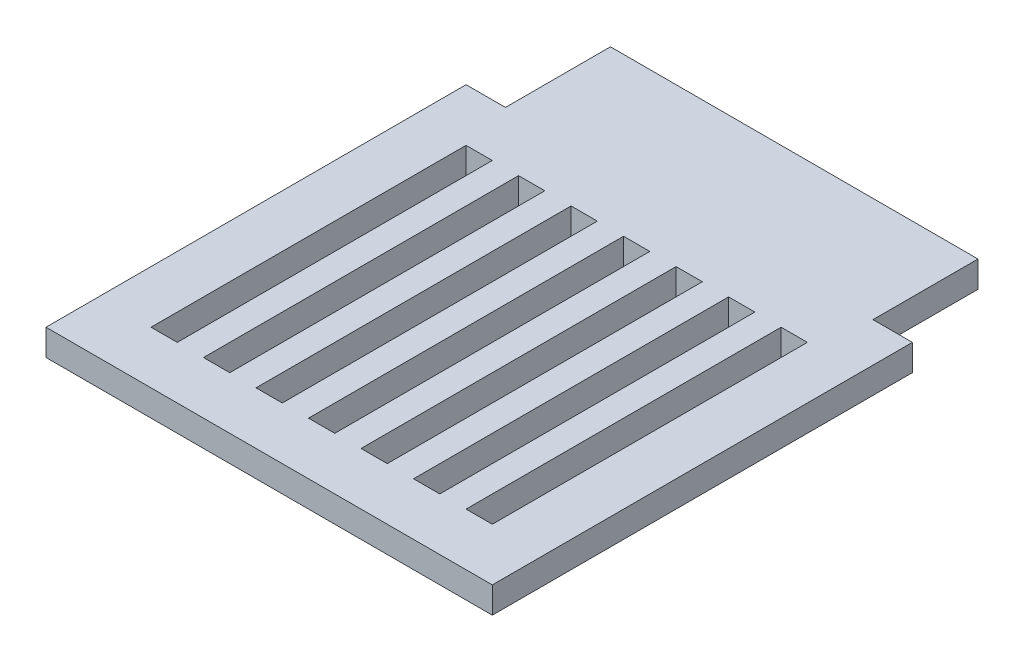
from build123d import *

# Parameters (mm, degrees)
EXTRUDE_1_DEPTH     = 1
SKETCH_5_W          = 1
SKETCH_5_H          = 12
CUT_EXTRUDE_2_DEPTH = 2


with BuildPart() as part:
    # 草图1 → 凸台-拉伸1 (new body)
    with BuildSketch(Plane(origin=(0, 0, 0), x_dir=(1, 0, 0), z_dir=(0, 1, 0))):
        Polygon((-8.5, -8), (-8.5, 8), (-7, 8), (-7, 12), (7, 12), (7, 8), (8.5, 8), (8.5, -8), align=None)
    extrude(amount=EXTRUDE_1_DEPTH)

    # 草图5 → 切除-拉伸2 (cut, through all)
    with BuildSketch(Plane(origin=(0, 1, 0), x_dir=(1, 0, 0), z_dir=(0, 1, 0))):
        Rectangle(SKETCH_5_W, SKETCH_5_H)
        with Locations((2, 0)):
            Rectangle(SKETCH_5_W, SKETCH_5_H)
        with Locations((6, 0)):
            Rectangle(SKETCH_5_W, SKETCH_5_H)
        with Locations((4, 0)):
            Rectangle(SKETCH_5_W, SKETCH_5_H)
        with Locations((-2, 0)):
            Rectangle(SKETCH_5_W, SKETCH_5_H)
        with Locations((-4, 0)):
            Rectangle(SKETCH_5_W, SKETCH_5_H)
        with Locations((-6, 0)):
            Rectangle(SKETCH_5_W, SKETCH_5_H)
    extrude(amount=-CUT_EXTRUDE_2_DEPTH, mode=Mode.SUBTRACT)


solid = part.part
